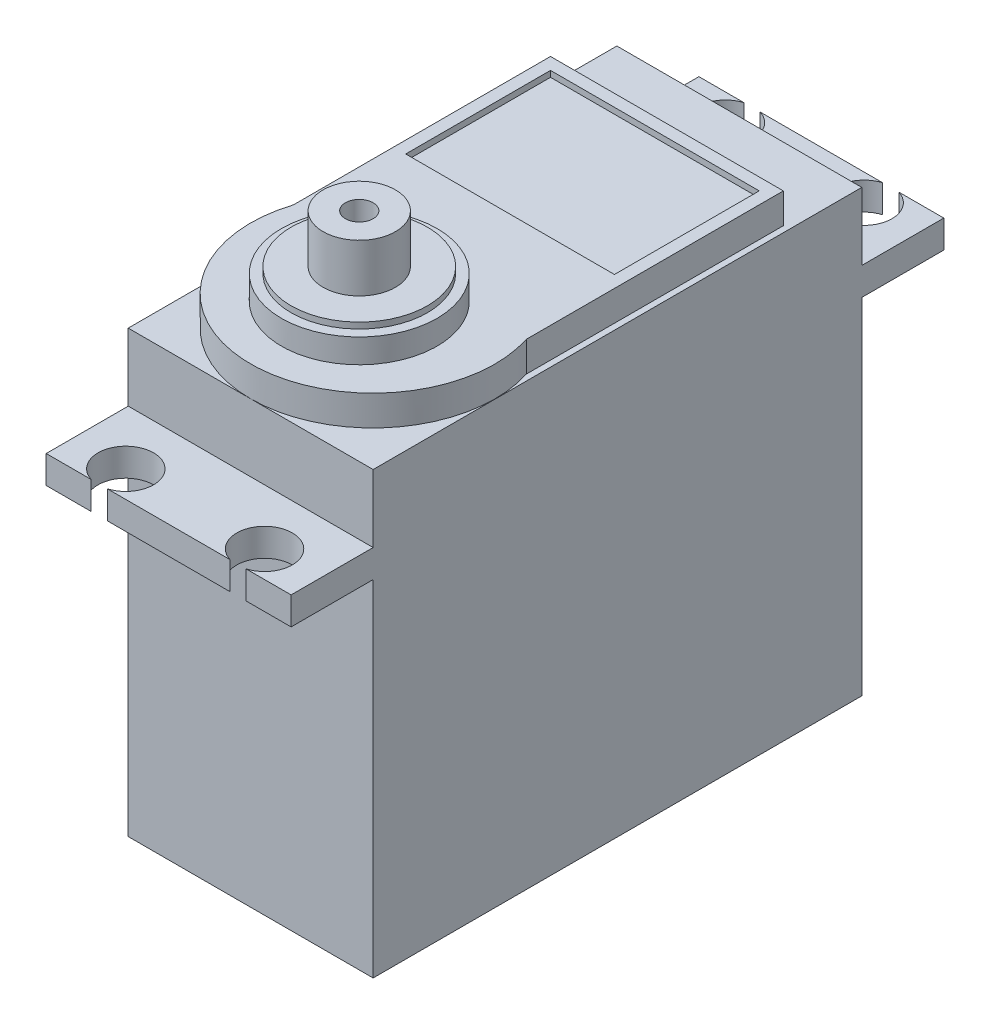
from build123d import *

# Parameters (mm, degrees)
SKETCH1_W           = 20.3
SKETCH1_H           = 40.5
BOSS_EXTRUDE1_DEPTH = 36.5
SKETCH4_W           = 20.3
SKETCH4_H           = 2.3
BOSS_EXTRUDE4_DEPTH = 6.8
SKETCH5_R           = 2.3
CUT_EXTRUDE1_DEPTH  = 2.3
BOSS_EXTRUDE5_DEPTH = 2.5
SKETCH10_R          = 6.45
BOSS_EXTRUDE6_DEPTH = 2
SKETCH11_R          = 5.65
BOSS_EXTRUDE7_DEPTH = 0.5
SKETCH12_R          = 3
BOSS_EXTRUDE8_DEPTH = 4
SKETCH13_R          = 1.15
CUT_EXTRUDE2_DEPTH  = 4
SKETCH14_W          = 17.3
SKETCH14_H          = 12
CUT_EXTRUDE3_DEPTH  = 0.5


with BuildPart() as part:
    # Sketch1 → Boss-Extrude1 (new body)
    with BuildSketch(Plane(origin=(0, 0, 0), x_dir=(1, 0, 0), z_dir=(0, 1, 0))):
        Rectangle(SKETCH1_W, SKETCH1_H)
    extrude(amount=BOSS_EXTRUDE1_DEPTH)

    # Sketch4 → Boss-Extrude4 (add)
    with BuildSketch(Plane.XY.offset(20.25)):
        with Locations((0, 29.75)):
            Rectangle(SKETCH4_W, SKETCH4_H)
    boss_extrude4 = extrude(amount=BOSS_EXTRUDE4_DEPTH)

    # Sketch5 → Cut-Extrude1 (cut)
    with BuildSketch(Plane(origin=(0, 30.9, 0), x_dir=(1, 0, 0), z_dir=(0, 1, 0))):
        with Locations((5.75, -24.85)):
            Circle(SKETCH5_R)
        with Locations((-5.75, -24.85)):
            Circle(SKETCH5_R)
    cut_extrude1 = extrude(amount=-CUT_EXTRUDE1_DEPTH, mode=Mode.SUBTRACT)

    # Mirror2: Boss-Extrude4, Cut-Extrude1 across plane
    add(boss_extrude4.mirror(Plane.XY))
    add(cut_extrude1.mirror(Plane.XY), mode=Mode.SUBTRACT)

    # Sketch7 → Boss-Extrude5 (add)
    with BuildSketch(Plane(origin=(0, 36.5, 0), x_dir=(1, 0, 0), z_dir=(0, 1, 0))):
        with BuildLine():
            Line((-9.65, 14.25), (-9.65, -7.05))
            ThreePointArc((-9.65, -7.05), (0, -20.25), (9.65, -7.05))
            Line((9.65, -7.05), (9.65, 14.25))
            Line((9.65, 14.25), (-9.65, 14.25))
        make_face()
    extrude(amount=BOSS_EXTRUDE5_DEPTH)

    # Sketch10 → Boss-Extrude6 (add)
    with BuildSketch(Plane(origin=(0, 39, 0), x_dir=(1, 0, 0), z_dir=(0, 1, 0))):
        with Locations((0, -11.25)):
            Circle(SKETCH10_R)
    extrude(amount=BOSS_EXTRUDE6_DEPTH)

    # Sketch11 → Boss-Extrude7 (add)
    with BuildSketch(Plane(origin=(0, 41, 0), x_dir=(1, 0, 0), z_dir=(0, 1, 0))):
        with Locations((0, -11.25)):
            Circle(SKETCH11_R)
    extrude(amount=BOSS_EXTRUDE7_DEPTH)

    # Sketch12 → Boss-Extrude8 (add)
    with BuildSketch(Plane(origin=(0, 41.5, 0), x_dir=(1, 0, 0), z_dir=(0, 1, 0))):
        with Locations((0, -11.25)):
            Circle(SKETCH12_R)
    extrude(amount=BOSS_EXTRUDE8_DEPTH)

    # Sketch13 → Cut-Extrude2 (cut)
    with BuildSketch(Plane(origin=(0, 45.5, 0), x_dir=(1, 0, 0), z_dir=(0, 1, 0))):
        with Locations((0, -11.25)):
            Circle(SKETCH13_R)
    extrude(amount=-CUT_EXTRUDE2_DEPTH, mode=Mode.SUBTRACT)

    # Sketch14 → Cut-Extrude3 (cut)
    with BuildSketch(Plane(origin=(0, 39, 0), x_dir=(1, 0, 0), z_dir=(0, 1, 0))):
        with Locations((0, 7.25)):
            Rectangle(SKETCH14_W, SKETCH14_H)
    extrude(amount=-CUT_EXTRUDE3_DEPTH, mode=Mode.SUBTRACT)


solid = part.part
